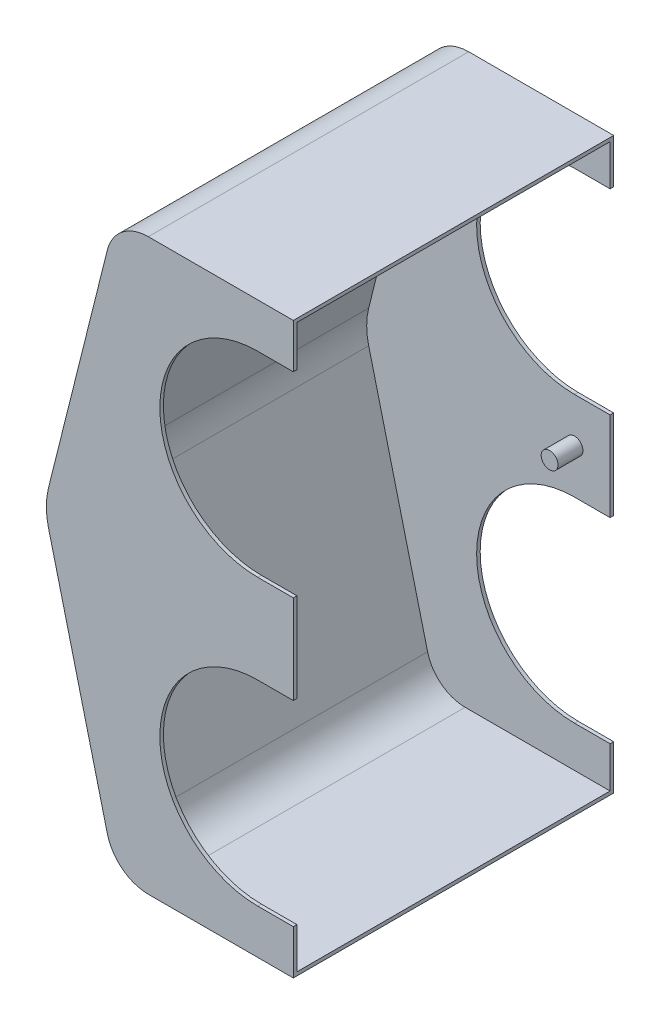
from build123d import *

# Parameters (mm, degrees)
SKETCH1_W           = 114.3
SKETCH1_H           = 203.2
BOSS_EXTRUDE1_DEPTH = 88.9
CUT_EXTRUDE1_DEPTH  = 115.3
FILLET1_R           = 25.24
FILLET2_R           = 15.08
CUT_EXTRUDE2_DEPTH  = 115.3
LPATTERN1_COUNT     = 2
LPATTERN1_PITCH     = 101.6
SHELL5_T            = -1.27
SKETCH9_R           = 3
BOSS_EXTRUDE2_DEPTH = 8.89


with BuildPart() as part:
    # Sketch1 → Boss-Extrude1 (new body)
    with BuildSketch(Plane(origin=(0, 0, 0), x_dir=(0, 0, -1), z_dir=(1, 0, 0))):
        with Locations((57.15, -101.6)):
            Rectangle(SKETCH1_W, SKETCH1_H)
    extrude(amount=-BOSS_EXTRUDE1_DEPTH)

    # Sketch4 → Cut-Extrude1 (cut, through all)
    with BuildSketch(Plane(origin=(0, 0, -114.3), x_dir=(-1, 0, 0), z_dir=(0, 0, -1))):
        Polygon((88.9, 0), (63.5, 0), (88.9, -101.6), align=None)
        Polygon((88.9, -203.2), (88.9, -101.6), (63.5, -203.2), align=None)
    extrude(amount=-CUT_EXTRUDE1_DEPTH, mode=Mode.SUBTRACT)

    # Fillet1
    fillet1_edges = [part.edges().sort_by_distance(p)[0] for p in [
        (-88.9, -101.6, -57.15),
    ]]
    fillet(fillet1_edges, radius=FILLET1_R)

    # Fillet2
    fillet2_edges = [part.edges().sort_by_distance(p)[0] for p in [
        (-63.5, 0, -57.15),
        (-63.5, -203.2, -57.15),
    ]]
    fillet(fillet2_edges, radius=FILLET2_R)

    # Sketch5 → Cut-Extrude2 (cut, through all)
    with BuildSketch(Plane.XY):
        with BuildLine():
            Line((-12.7, -187.325), (0, -187.325))
            Line((0, -187.325), (0, -117.475))
            Line((0, -117.475), (-12.7, -117.475))
            ThreePointArc((-12.7, -117.475), (-47.625, -152.4), (-12.7, -187.325))
        make_face()
    cut_extrude2 = extrude(amount=-CUT_EXTRUDE2_DEPTH, mode=Mode.SUBTRACT)

    # LPattern1: Cut-Extrude2 ×2
    with Locations(*[(0, i * LPATTERN1_PITCH, 0) for i in range(1, LPATTERN1_COUNT)]):
        add(cut_extrude2, mode=Mode.SUBTRACT)

    # Shell5
    shell5_openings = [part.faces().sort_by_distance(p)[0] for p in [
        (0, -195.2625, -57.15),
        (0, -101.6, -57.15),
        (-30.1625, -152.4, -57.15),
        (-6.35, -117.475, -57.15),
        (-6.35, -187.325, -57.15),
        (0, -7.9375, -57.15),
        (-30.1625, -50.8, -57.15),
        (-6.35, -15.875, -57.15),
        (-6.35, -85.725, -57.15),
    ]]
    offset(amount=SHELL5_T, openings=shell5_openings, kind=Kind.INTERSECTION)

    # Sketch9 → Boss-Extrude2 (add)
    with BuildSketch(Plane.XY.offset(-113.03)):
        with Locations((-12.7, -101.6)):
            Circle(SKETCH9_R)
    boss_extrude2 = extrude(amount=BOSS_EXTRUDE2_DEPTH)

    # Mirror1: Boss-Extrude2 across plane
    add(boss_extrude2.mirror(Plane.XY.offset(-57.15)))


solid = part.part
